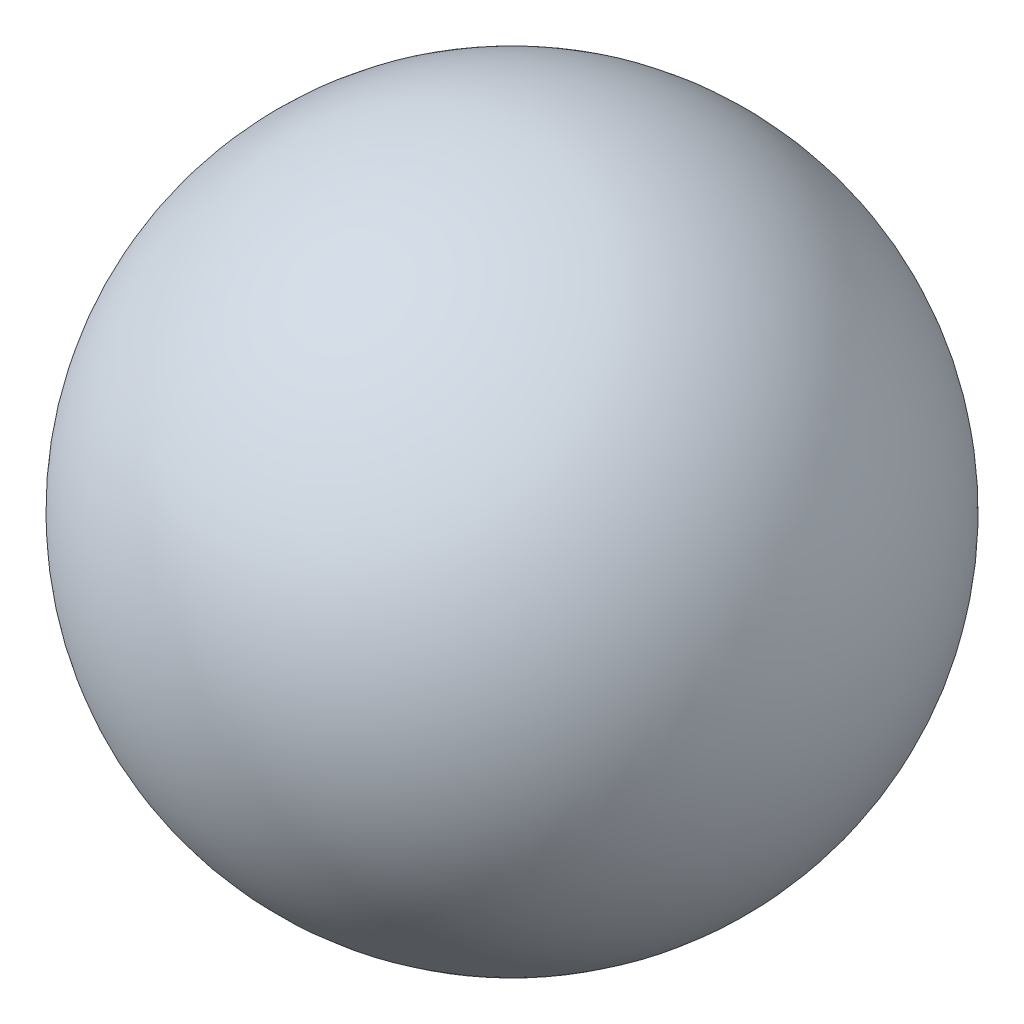
from build123d import *

# Parameters (mm, degrees)
SHELL5_T = -1.25


with BuildPart() as part:
    # Sketch2 → Revolve1 (revolve)
    with BuildSketch(Plane.XY):
        with BuildLine():
            Line((0, 40), (0, -37.996710384))
            Line((0, -37.996710384), (12.5, -37.996710384))
            ThreePointArc((12.5, -37.996710384), (39.496002427, 6.329754523), (0, 40))
        make_face()
    revolve(axis=Axis((0, 40, 0), (0, -1, 0)))

    # Shell5
    shell5_openings = [part.faces().sort_by_distance(p)[0] for p in [
        (0, -37.996710384, 0),
    ]]
    offset(amount=SHELL5_T, openings=shell5_openings, kind=Kind.INTERSECTION)


solid = part.part
